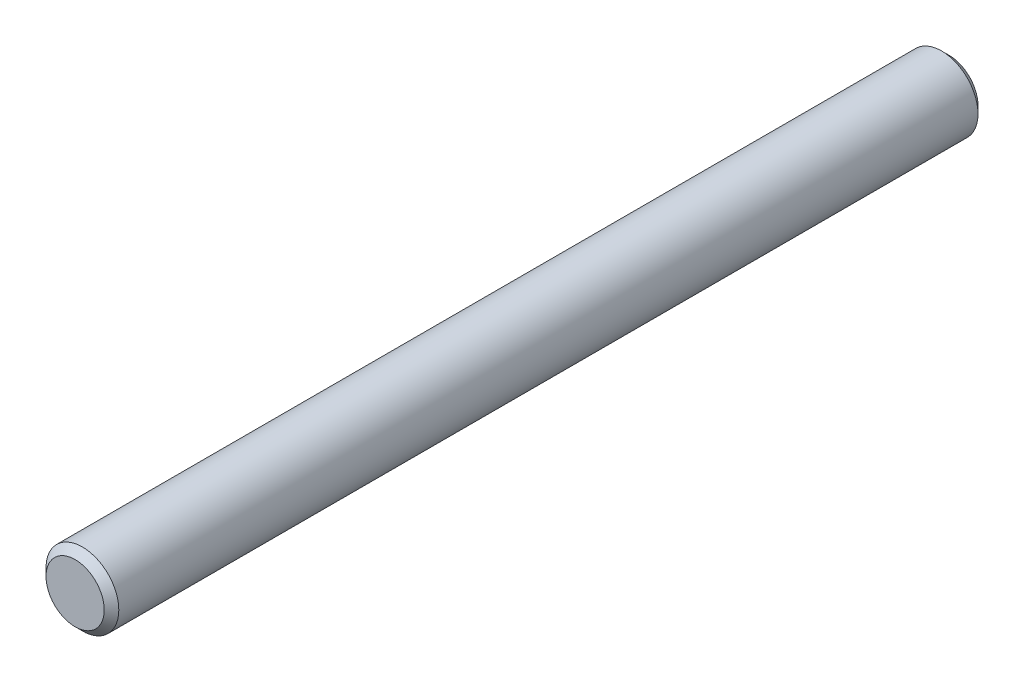
from build123d import *

# Parameters (mm, degrees)
SKETCH1_R      = 3.175
EXTRUDE1_DEPTH = 38.1
CHAMFER1_SIZE  = 0.635


with BuildPart() as part:
    # Sketch1 → Extrude1 (new body, symmetric)
    with BuildSketch(Plane.XY):
        Circle(SKETCH1_R)
    extrude(amount=EXTRUDE1_DEPTH, both=True)

    # Chamfer1
    chamfer1_edges = [part.edges().sort_by_distance(p)[0] for p in [
        (-3.175, 0, -38.1),
        (-3.175, 0, 38.1),
    ]]
    chamfer(chamfer1_edges, length=CHAMFER1_SIZE)


solid = part.part
